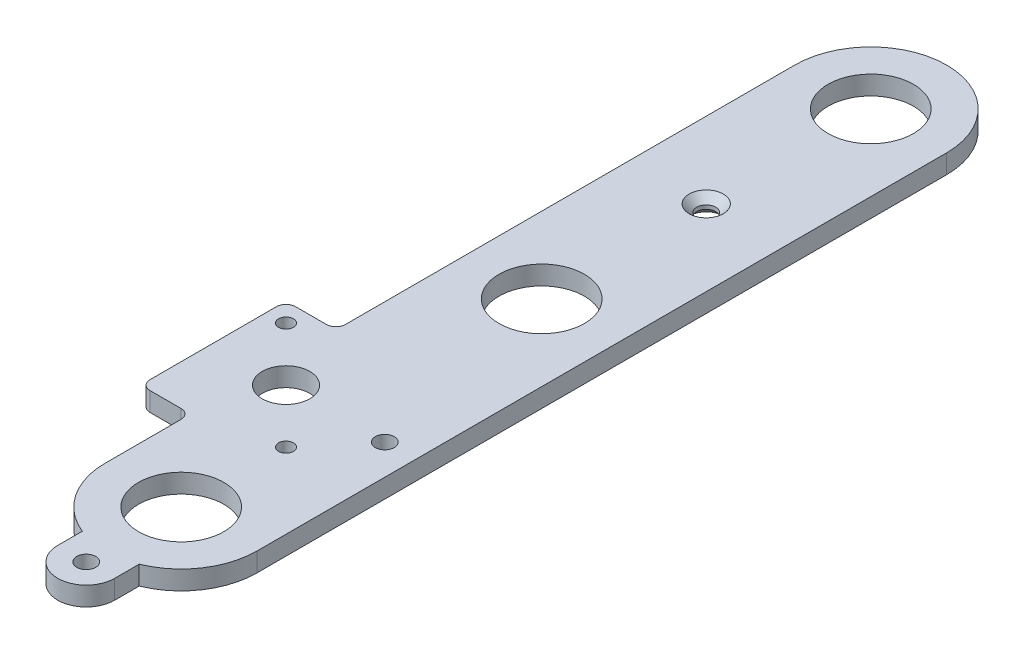
from build123d import *

# Parameters (mm, degrees)
SKETCH3_R           = 14.2748
SKETCH3_R_2         = 7.9375
SKETCH3_R_3         = 2.4892
SKETCH3_R_4         = 3.175
BOSS_EXTRUDE1_DEPTH = 6.35
CHAMFER1_SIZE       = 2.54


with BuildPart() as part:
    # Sketch3 → Boss-Extrude1 (new body)
    with BuildSketch(Plane(origin=(0, 0, 0), x_dir=(1, 0, 0), z_dir=(0, 1, 0))):
        with BuildLine():
            Line((-249.735512242, 346.01236887), (-239.395, 346.01236887))
            ThreePointArc((-239.395, 346.01236887), (-237.14993597, 345.0824329), (-236.22, 342.83736887))
            Line((-236.22, 342.83736887), (-236.22, 317.5))
            ThreePointArc((-236.22, 317.5), (-231.880567419, 303.300968343), (-220.345, 293.953569803))
            Line((-220.345, 293.953569803), (-220.345, 285.75))
            ThreePointArc((-220.345, 285.75), (-210.82, 276.225), (-201.295, 285.75))
            Line((-201.295, 285.75), (-201.295, 293.953569803))
            ThreePointArc((-201.295, 293.953569803), (-189.759432581, 303.300968343), (-185.42, 317.5))
            Line((-185.42, 317.5), (-185.42, 548.034576396))
            ThreePointArc((-185.42, 548.034576396), (-210.82, 573.434576396), (-236.22, 548.034576396))
            Line((-236.22, 548.034576396), (-236.22, 397.808393354))
            ThreePointArc((-236.22, 397.808393354), (-237.14993597, 395.563329324), (-239.395, 394.633393354))
            Line((-239.395, 394.633393354), (-249.735512242, 394.633393354))
            ThreePointArc((-249.735512242, 394.633393354), (-251.980576272, 393.703457384), (-252.910512242, 391.458393354))
            Line((-252.910512242, 391.458393354), (-252.910512242, 349.18736887))
            ThreePointArc((-252.910512242, 349.18736887), (-251.980576272, 346.942304839), (-249.735512242, 346.01236887))
        make_face()
        with Locations((-210.82, 548.034576396)):
            Circle(SKETCH3_R, mode=Mode.SUBTRACT)
        with Locations((-210.82, 438.027176396)):
            Circle(SKETCH3_R, mode=Mode.SUBTRACT)
        with Locations((-210.82, 317.5)):
            Circle(SKETCH3_R, mode=Mode.SUBTRACT)
        with Locations((-228.6, 370.322881112)):
            Circle(SKETCH3_R_2, mode=Mode.SUBTRACT)
        with Locations((-246.560512242, 388.283393354)):
            Circle(SKETCH3_R_3, mode=Mode.SUBTRACT)
        with Locations((-210.639487758, 352.36236887)):
            Circle(SKETCH3_R_3, mode=Mode.SUBTRACT)
        with Locations((-210.82, 285.75)):
            Circle(SKETCH3_R_4, mode=Mode.SUBTRACT)
        with Locations((-210.82, 493.030876396)):
            Circle(SKETCH3_R_4, mode=Mode.SUBTRACT)
        with Locations((-195.58, 370.322881112)):
            Circle(SKETCH3_R_4, mode=Mode.SUBTRACT)
    extrude(amount=BOSS_EXTRUDE1_DEPTH)

    # Chamfer1
    chamfer1_edges = [part.edges().sort_by_distance(p)[0] for p in [
        (-213.995, 6.35, -493.030876396),
        (-213.995, 0, -493.030876396),
    ]]
    chamfer(chamfer1_edges, length=CHAMFER1_SIZE)


solid = part.part
